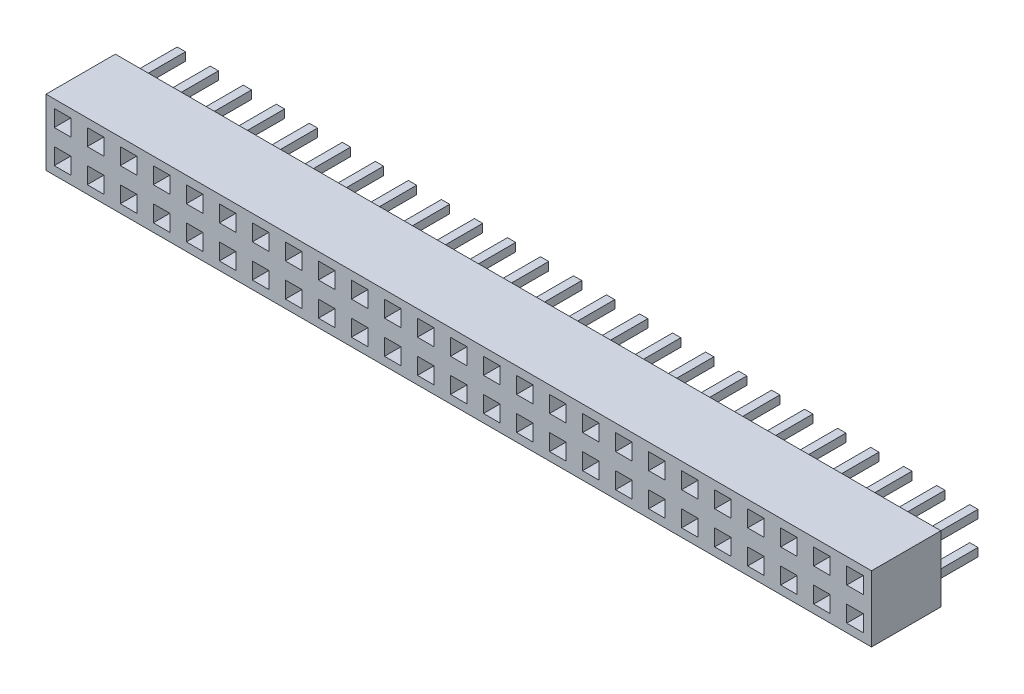
from build123d import *

# Parameters (mm, degrees)
SKETCH1_W           = 50
SKETCH1_H           = 4
BOSS_EXTRUDE1_DEPTH = 4.2
SKETCH3_W           = 1
SKETCH3_H           = 1
CUT_EXTRUDE1_DEPTH  = 3
SKETCH4_W           = 0.5
SKETCH4_H           = 0.5
BOSS_EXTRUDE2_DEPTH = 3


with BuildPart() as part:
    # Sketch1 → Boss-Extrude1 (new body)
    with BuildSketch(Plane.XY):
        Rectangle(SKETCH1_W, SKETCH1_H)
    extrude(amount=BOSS_EXTRUDE1_DEPTH)

    # Sketch3 → Cut-Extrude1 (cut)
    with BuildSketch(Plane.XY.offset(4.2)):
        with Locations((-24, 1)):
            Rectangle(SKETCH3_W, SKETCH3_H)
        with Locations((-24, -1)):
            Rectangle(SKETCH3_W, SKETCH3_H)
        with Locations((-22, 1)):
            Rectangle(SKETCH3_W, SKETCH3_H)
        with Locations((-20, 1)):
            Rectangle(SKETCH3_W, SKETCH3_H)
        with Locations((-18, 1)):
            Rectangle(SKETCH3_W, SKETCH3_H)
        with Locations((-16, 1)):
            Rectangle(SKETCH3_W, SKETCH3_H)
        with Locations((-14, 1)):
            Rectangle(SKETCH3_W, SKETCH3_H)
        with Locations((-12, 1)):
            Rectangle(SKETCH3_W, SKETCH3_H)
        with Locations((-10, 1)):
            Rectangle(SKETCH3_W, SKETCH3_H)
        with Locations((-8, 1)):
            Rectangle(SKETCH3_W, SKETCH3_H)
        with Locations((-6, 1)):
            Rectangle(SKETCH3_W, SKETCH3_H)
        with Locations((-4, 1)):
            Rectangle(SKETCH3_W, SKETCH3_H)
        with Locations((-2, 1)):
            Rectangle(SKETCH3_W, SKETCH3_H)
        with Locations((0, 1)):
            Rectangle(SKETCH3_W, SKETCH3_H)
        with Locations((2, 1)):
            Rectangle(SKETCH3_W, SKETCH3_H)
        with Locations((4, 1)):
            Rectangle(SKETCH3_W, SKETCH3_H)
        with Locations((6, 1)):
            Rectangle(SKETCH3_W, SKETCH3_H)
        with Locations((8, 1)):
            Rectangle(SKETCH3_W, SKETCH3_H)
        with Locations((10, 1)):
            Rectangle(SKETCH3_W, SKETCH3_H)
        with Locations((12, 1)):
            Rectangle(SKETCH3_W, SKETCH3_H)
        with Locations((14, 1)):
            Rectangle(SKETCH3_W, SKETCH3_H)
        with Locations((16, 1)):
            Rectangle(SKETCH3_W, SKETCH3_H)
        with Locations((18, 1)):
            Rectangle(SKETCH3_W, SKETCH3_H)
        with Locations((20, 1)):
            Rectangle(SKETCH3_W, SKETCH3_H)
        with Locations((22, 1)):
            Rectangle(SKETCH3_W, SKETCH3_H)
        with Locations((24, 1)):
            Rectangle(SKETCH3_W, SKETCH3_H)
        with Locations((-22, -1)):
            Rectangle(SKETCH3_W, SKETCH3_H)
        with Locations((-20, -1)):
            Rectangle(SKETCH3_W, SKETCH3_H)
        with Locations((-18, -1)):
            Rectangle(SKETCH3_W, SKETCH3_H)
        with Locations((-16, -1)):
            Rectangle(SKETCH3_W, SKETCH3_H)
        with Locations((-14, -1)):
            Rectangle(SKETCH3_W, SKETCH3_H)
        with Locations((-12, -1)):
            Rectangle(SKETCH3_W, SKETCH3_H)
        with Locations((-10, -1)):
            Rectangle(SKETCH3_W, SKETCH3_H)
        with Locations((-8, -1)):
            Rectangle(SKETCH3_W, SKETCH3_H)
        with Locations((-6, -1)):
            Rectangle(SKETCH3_W, SKETCH3_H)
        with Locations((-4, -1)):
            Rectangle(SKETCH3_W, SKETCH3_H)
        with Locations((-2, -1)):
            Rectangle(SKETCH3_W, SKETCH3_H)
        with Locations((0, -1)):
            Rectangle(SKETCH3_W, SKETCH3_H)
        with Locations((2, -1)):
            Rectangle(SKETCH3_W, SKETCH3_H)
        with Locations((4, -1)):
            Rectangle(SKETCH3_W, SKETCH3_H)
        with Locations((6, -1)):
            Rectangle(SKETCH3_W, SKETCH3_H)
        with Locations((8, -1)):
            Rectangle(SKETCH3_W, SKETCH3_H)
        with Locations((10, -1)):
            Rectangle(SKETCH3_W, SKETCH3_H)
        with Locations((12, -1)):
            Rectangle(SKETCH3_W, SKETCH3_H)
        with Locations((14, -1)):
            Rectangle(SKETCH3_W, SKETCH3_H)
        with Locations((16, -1)):
            Rectangle(SKETCH3_W, SKETCH3_H)
        with Locations((18, -1)):
            Rectangle(SKETCH3_W, SKETCH3_H)
        with Locations((20, -1)):
            Rectangle(SKETCH3_W, SKETCH3_H)
        with Locations((22, -1)):
            Rectangle(SKETCH3_W, SKETCH3_H)
        with Locations((24, -1)):
            Rectangle(SKETCH3_W, SKETCH3_H)
    extrude(amount=-CUT_EXTRUDE1_DEPTH, mode=Mode.SUBTRACT)

    # Sketch4 → Boss-Extrude2 (add)
    with BuildSketch(Plane(origin=(0, 0, 0), x_dir=(-1, 0, 0), z_dir=(0, 0, -1))):
        with Locations((-24, 1)):
            Rectangle(SKETCH4_W, SKETCH4_H)
        with Locations((-24, -1)):
            Rectangle(SKETCH4_W, SKETCH4_H)
        with Locations((-22, -1)):
            Rectangle(SKETCH4_W, SKETCH4_H)
        with Locations((-22, 1)):
            Rectangle(SKETCH4_W, SKETCH4_H)
        with Locations((-20, -1)):
            Rectangle(SKETCH4_W, SKETCH4_H)
        with Locations((-20, 1)):
            Rectangle(SKETCH4_W, SKETCH4_H)
        with Locations((-18, -1)):
            Rectangle(SKETCH4_W, SKETCH4_H)
        with Locations((-18, 1)):
            Rectangle(SKETCH4_W, SKETCH4_H)
        with Locations((-16, -1)):
            Rectangle(SKETCH4_W, SKETCH4_H)
        with Locations((-16, 1)):
            Rectangle(SKETCH4_W, SKETCH4_H)
        with Locations((-14, -1)):
            Rectangle(SKETCH4_W, SKETCH4_H)
        with Locations((-14, 1)):
            Rectangle(SKETCH4_W, SKETCH4_H)
        with Locations((-12, -1)):
            Rectangle(SKETCH4_W, SKETCH4_H)
        with Locations((-12, 1)):
            Rectangle(SKETCH4_W, SKETCH4_H)
        with Locations((-10, -1)):
            Rectangle(SKETCH4_W, SKETCH4_H)
        with Locations((-10, 1)):
            Rectangle(SKETCH4_W, SKETCH4_H)
        with Locations((-8, -1)):
            Rectangle(SKETCH4_W, SKETCH4_H)
        with Locations((-8, 1)):
            Rectangle(SKETCH4_W, SKETCH4_H)
        with Locations((-6, -1)):
            Rectangle(SKETCH4_W, SKETCH4_H)
        with Locations((-6, 1)):
            Rectangle(SKETCH4_W, SKETCH4_H)
        with Locations((-4, -1)):
            Rectangle(SKETCH4_W, SKETCH4_H)
        with Locations((-4, 1)):
            Rectangle(SKETCH4_W, SKETCH4_H)
        with Locations((-2, -1)):
            Rectangle(SKETCH4_W, SKETCH4_H)
        with Locations((-2, 1)):
            Rectangle(SKETCH4_W, SKETCH4_H)
        with Locations((0, -1)):
            Rectangle(SKETCH4_W, SKETCH4_H)
        with Locations((0, 1)):
            Rectangle(SKETCH4_W, SKETCH4_H)
        with Locations((2, -1)):
            Rectangle(SKETCH4_W, SKETCH4_H)
        with Locations((2, 1)):
            Rectangle(SKETCH4_W, SKETCH4_H)
        with Locations((4, -1)):
            Rectangle(SKETCH4_W, SKETCH4_H)
        with Locations((4, 1)):
            Rectangle(SKETCH4_W, SKETCH4_H)
        with Locations((6, -1)):
            Rectangle(SKETCH4_W, SKETCH4_H)
        with Locations((6, 1)):
            Rectangle(SKETCH4_W, SKETCH4_H)
        with Locations((8, -1)):
            Rectangle(SKETCH4_W, SKETCH4_H)
        with Locations((8, 1)):
            Rectangle(SKETCH4_W, SKETCH4_H)
        with Locations((10, -1)):
            Rectangle(SKETCH4_W, SKETCH4_H)
        with Locations((10, 1)):
            Rectangle(SKETCH4_W, SKETCH4_H)
        with Locations((12, -1)):
            Rectangle(SKETCH4_W, SKETCH4_H)
        with Locations((12, 1)):
            Rectangle(SKETCH4_W, SKETCH4_H)
        with Locations((14, -1)):
            Rectangle(SKETCH4_W, SKETCH4_H)
        with Locations((14, 1)):
            Rectangle(SKETCH4_W, SKETCH4_H)
        with Locations((16, -1)):
            Rectangle(SKETCH4_W, SKETCH4_H)
        with Locations((16, 1)):
            Rectangle(SKETCH4_W, SKETCH4_H)
        with Locations((18, -1)):
            Rectangle(SKETCH4_W, SKETCH4_H)
        with Locations((18, 1)):
            Rectangle(SKETCH4_W, SKETCH4_H)
        with Locations((20, -1)):
            Rectangle(SKETCH4_W, SKETCH4_H)
        with Locations((20, 1)):
            Rectangle(SKETCH4_W, SKETCH4_H)
        with Locations((22, -1)):
            Rectangle(SKETCH4_W, SKETCH4_H)
        with Locations((22, 1)):
            Rectangle(SKETCH4_W, SKETCH4_H)
        with Locations((24, -1)):
            Rectangle(SKETCH4_W, SKETCH4_H)
        with Locations((24, 1)):
            Rectangle(SKETCH4_W, SKETCH4_H)
    extrude(amount=BOSS_EXTRUDE2_DEPTH)


solid = part.part
